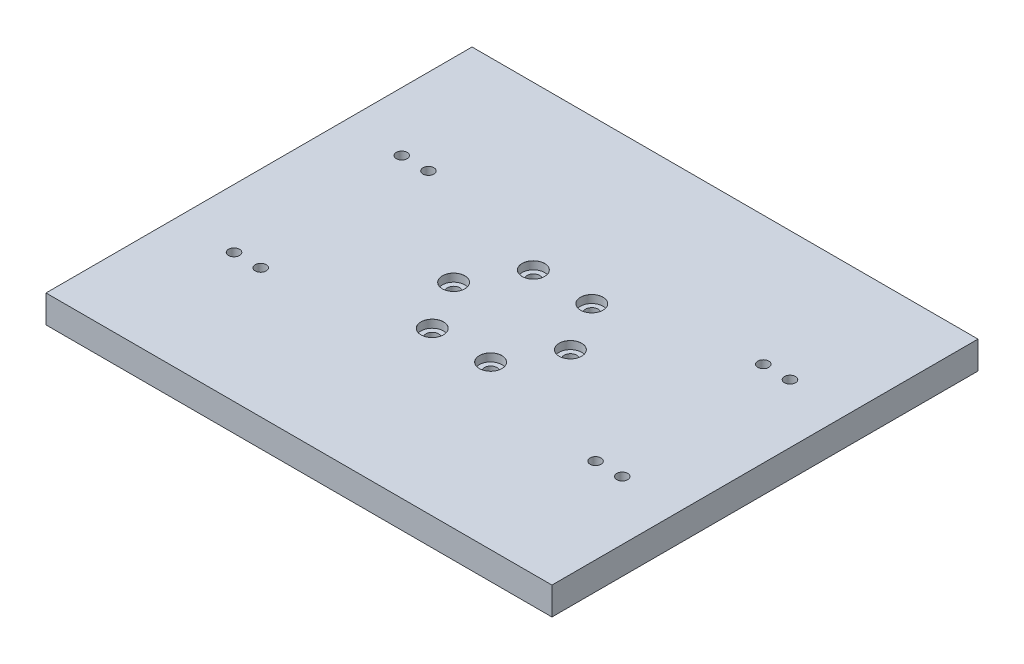
from build123d import *

# Parameters (mm, degrees)
SKETCH1_W                               = 482.6
SKETCH1_H                               = 406.4
BOSS_EXTRUDE1_DEPTH                     = 26.416
SKETCH3_R                               = 1.27
SKETCH3_R_2                             = 5.25
CUT_EXTRUDE2_DEPTH                      = 27.416
CBORE_FOR_M10_HEX_HEAD_BOLT1_AT_2_COUNT = 2
CBORE_FOR_M10_HEX_HEAD_BOLT1_AT_2_PITCH = 55.7
CBORE_FOR_M10_HEX_HEAD_BOLT1_AT_3_COUNT = 2
CBORE_FOR_M10_HEX_HEAD_BOLT1_AT_3_PITCH = 96.475229982
CBORE_FOR_M10_HEX_HEAD_BOLT1_AT_4_COUNT = 2
CBORE_FOR_M10_HEX_HEAD_BOLT1_AT_4_PITCH = 111.4
CBORE_FOR_M10_HEX_HEAD_BOLT1_AT_5_COUNT = 2
CBORE_FOR_M10_HEX_HEAD_BOLT1_AT_5_PITCH = 96.475229982
CBORE_FOR_M10_HEX_HEAD_BOLT1_AT_6_COUNT = 2
CBORE_FOR_M10_HEX_HEAD_BOLT1_AT_6_PITCH = 55.7
TAP_DRILL_FOR_M10_HELICOIL1_D           = 10.5


with BuildPart() as part:
    # Sketch1 → Boss-Extrude1 (new body)
    with BuildSketch(Plane(origin=(0, 0, 0), x_dir=(1, 0, 0), z_dir=(0, 1, 0))):
        Rectangle(SKETCH1_W, SKETCH1_H)
    extrude(amount=BOSS_EXTRUDE1_DEPTH)

    # Sketch3 → Cut-Extrude2 (cut, through all)
    with BuildSketch(Plane(origin=(0, 26.416, 0), x_dir=(1, 0, 0), z_dir=(0, 1, 0))):
        with Locations((-185.152559706, -80.01)):
            Circle(SKETCH3_R)
        with Locations((-159.68726, -80.01)):
            Circle(SKETCH3_R)
        with Locations((-185.152559706, 80.01)):
            Circle(SKETCH3_R)
        with Locations((-159.68726, 80.01)):
            Circle(SKETCH3_R)
        with Locations((159.68726, -80.01)):
            Circle(SKETCH3_R)
        with Locations((185.152559706, -80.01)):
            Circle(SKETCH3_R)
        with Locations((185.152559706, 80.01)):
            Circle(SKETCH3_R)
        with Locations((159.68726, 80.01)):
            Circle(SKETCH3_R)
        with Locations((55.7, 0)):
            Circle(SKETCH3_R_2)
        with Locations((27.85, -48.237614991)):
            Circle(SKETCH3_R_2)
        with Locations((-27.85, -48.237614991)):
            Circle(SKETCH3_R_2)
        with Locations((-55.7, 0)):
            Circle(SKETCH3_R_2)
        with Locations((-27.85, 48.237614991)):
            Circle(SKETCH3_R_2)
        with Locations((27.85, 48.237614991)):
            Circle(SKETCH3_R_2)
    extrude(amount=-CUT_EXTRUDE2_DEPTH, mode=Mode.SUBTRACT)

    # Sketch11 → CBORE for M10 Hex Head Bolt1 (revolve, cut)
    with BuildSketch(Plane(origin=(27.85, 26.416, -48.237614991), x_dir=(0, 0, 1), z_dir=(1, 0, 0))):
        Polygon((0, 0), (0, 26.416), (6, 26.416), (6, 7.5), (10.74, 7.5), (10.74, 0.025), (10.765, 0), align=None)
    cbore_for_m10_hex_head_bolt1 = revolve(axis=Axis((27.85, 32.766, -48.237614991), (0, -1, 0)), mode=Mode.SUBTRACT)

    # CBORE for M10 Hex Head Bolt1 at 2: CBORE for M10 Hex Head Bolt1 ×2
    with Locations(*[Vector(0.5, 0, 0.866025404) * (i * CBORE_FOR_M10_HEX_HEAD_BOLT1_AT_2_PITCH) for i in range(1, CBORE_FOR_M10_HEX_HEAD_BOLT1_AT_2_COUNT)]):
        add(cbore_for_m10_hex_head_bolt1, mode=Mode.SUBTRACT)

    # CBORE for M10 Hex Head Bolt1 at 3: CBORE for M10 Hex Head Bolt1 ×2
    with Locations(*[(0, 0, i * CBORE_FOR_M10_HEX_HEAD_BOLT1_AT_3_PITCH) for i in range(1, CBORE_FOR_M10_HEX_HEAD_BOLT1_AT_3_COUNT)]):
        add(cbore_for_m10_hex_head_bolt1, mode=Mode.SUBTRACT)

    # CBORE for M10 Hex Head Bolt1 at 4: CBORE for M10 Hex Head Bolt1 ×2
    with Locations(*[Vector(-0.5, 0, 0.866025404) * (i * CBORE_FOR_M10_HEX_HEAD_BOLT1_AT_4_PITCH) for i in range(1, CBORE_FOR_M10_HEX_HEAD_BOLT1_AT_4_COUNT)]):
        add(cbore_for_m10_hex_head_bolt1, mode=Mode.SUBTRACT)

    # CBORE for M10 Hex Head Bolt1 at 5: CBORE for M10 Hex Head Bolt1 ×2
    with Locations(*[Vector(-0.866025404, 0, 0.5) * (i * CBORE_FOR_M10_HEX_HEAD_BOLT1_AT_5_PITCH) for i in range(1, CBORE_FOR_M10_HEX_HEAD_BOLT1_AT_5_COUNT)]):
        add(cbore_for_m10_hex_head_bolt1, mode=Mode.SUBTRACT)

    # CBORE for M10 Hex Head Bolt1 at 6: CBORE for M10 Hex Head Bolt1 ×2
    with Locations(*[(-i * CBORE_FOR_M10_HEX_HEAD_BOLT1_AT_6_PITCH, 0, 0) for i in range(1, CBORE_FOR_M10_HEX_HEAD_BOLT1_AT_6_COUNT)]):
        add(cbore_for_m10_hex_head_bolt1, mode=Mode.SUBTRACT)

    # Tap Drill for M10 Helicoil1 (through all)
    with Locations(Plane(origin=(0, 26.416, 0), x_dir=(1, 0, 0), z_dir=(0, 1, 0))):
        with Locations((-185.152559706, -80.01), (-159.68726, -80.01), (-185.152559706, 80.01), (-159.68726, 80.01), (185.152559706, 80.01), (159.68726, 80.01), (185.152559706, -80.01), (159.68726, -80.01)):
            Hole(TAP_DRILL_FOR_M10_HELICOIL1_D / 2)


solid = part.part
